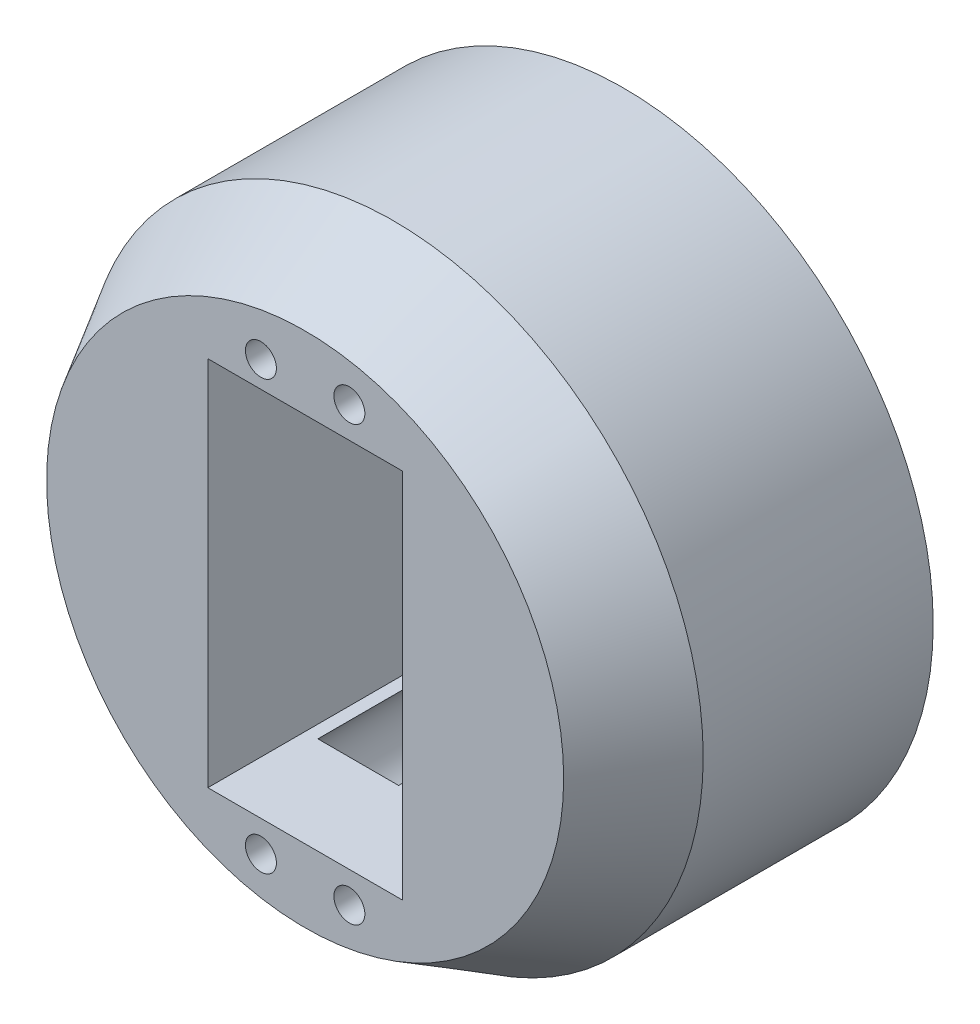
from build123d import *

# Parameters (mm, degrees)
SKETCH1_R           = 35
BOSS_EXTRUDE1_DEPTH = 36
CHAMFER1_SIZE       = 10
CHAMFER1_SIZE2      = 5.773502692
SKETCH2_W           = 22
SKETCH2_H           = 42
CUT_EXTRUDE1_DEPTH  = 37
SKETCH3_R           = 1.75
CUT_EXTRUDE2_DEPTH  = 37
SKETCH4_R           = 1.75
CUT_EXTRUDE3_DEPTH  = 25


with BuildPart() as part:
    # Sketch1 → Boss-Extrude1 (new body)
    with BuildSketch(Plane.XY):
        Circle(SKETCH1_R)
    extrude(amount=BOSS_EXTRUDE1_DEPTH)

    # Chamfer1
    chamfer1_edges = [part.edges().sort_by_distance(p)[0] for p in [
        (-35, 0, 36),
    ]]
    chamfer1_side = [part.faces().sort_by_distance(p)[0] for p in [
        (-35, 0, 18),
    ]]
    chamfer(chamfer1_edges, length=CHAMFER1_SIZE, length2=CHAMFER1_SIZE2, reference=chamfer1_side[0])

    # Sketch2 → Cut-Extrude1 (cut, through all)
    with BuildSketch(Plane.XY.offset(36)):
        Rectangle(SKETCH2_W, SKETCH2_H)
    extrude(amount=-CUT_EXTRUDE1_DEPTH, mode=Mode.SUBTRACT)

    # Sketch3 → Cut-Extrude2 (cut, through all)
    with BuildSketch(Plane.XY.offset(36)):
        with Locations((-5, 23.927118757)):
            Circle(SKETCH3_R)
        with Locations((5, 24.5)):
            Circle(SKETCH3_R)
        with Locations((5, -24.5)):
            Circle(SKETCH3_R)
        with Locations((-5, -24.5)):
            Circle(SKETCH3_R)
    extrude(amount=-CUT_EXTRUDE2_DEPTH, mode=Mode.SUBTRACT)

    # Sketch4 → Cut-Extrude3 (cut)
    with BuildSketch(Plane(origin=(0, 0, 0), x_dir=(-1, 0, 0), z_dir=(0, 0, -1))):
        with BuildLine():
            ThreePointArc((0, -21.660545827), (-10.75, -24.5), (0, -27.339454173))
            ThreePointArc((0, -27.339454173), (10.75, -24.5), (0, -21.660545827))
        make_face()
        with Locations((-5, -24.5)):
            Circle(SKETCH4_R, mode=Mode.SUBTRACT)
        with Locations((5, -24.5)):
            Circle(SKETCH4_R, mode=Mode.SUBTRACT)
        with BuildLine():
            ThreePointArc((-0.161572278, 21.393214334), (10.740587615, 23.59825126), (0.161572278, 27.033904423))
            ThreePointArc((0.161572278, 27.033904423), (-10.740587615, 24.828867497), (-0.161572278, 21.393214334))
        make_face()
        with Locations((5, 23.927118757)):
            Circle(SKETCH4_R, mode=Mode.SUBTRACT)
        with Locations((-5, 24.5)):
            Circle(SKETCH4_R, mode=Mode.SUBTRACT)
    extrude(amount=-CUT_EXTRUDE3_DEPTH, mode=Mode.SUBTRACT)


solid = part.part
